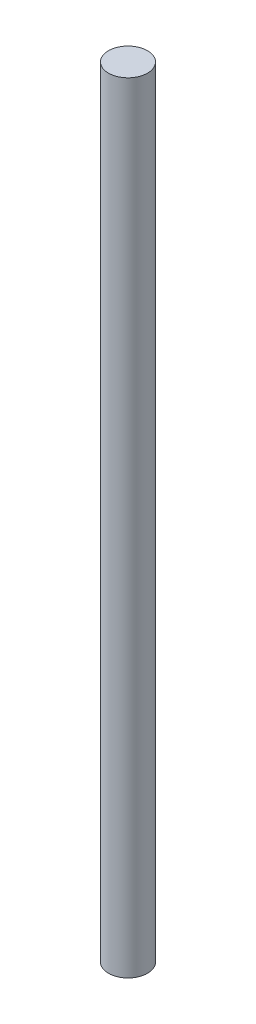
from build123d import *

# Parameters (mm, degrees)
SKETCH1_R           = 0.125
BOSS_EXTRUDE1_DEPTH = 5


with BuildPart() as part:
    # Sketch1 → Boss-Extrude1 (new body)
    with BuildSketch(Plane(origin=(0, 0, 0), x_dir=(1, 0, 0), z_dir=(0, 1, 0))):
        Circle(SKETCH1_R)
    extrude(amount=BOSS_EXTRUDE1_DEPTH)


solid = part.part
